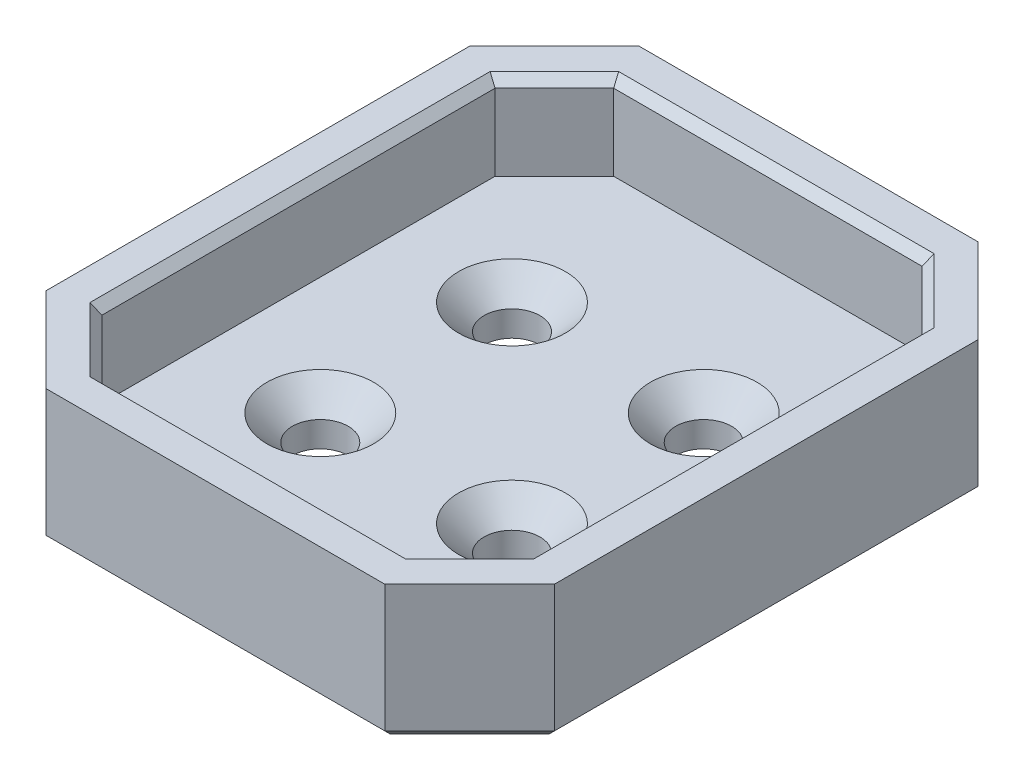
from build123d import *

# Parameters (mm, degrees)
SKETCH1_W                                      = 30
SKETCH1_H                                      = 35
BOSS_EXTRUDE1_DEPTH                            = 3
SKETCH2_W                                      = 30
SKETCH2_H                                      = 35
BOSS_EXTRUDE2_DEPTH                            = 5
CHAMFER1_SIZE                                  = 5
CSK_FOR_M3_FLAT_HEAD_MACHINE_SCREW1_AT_2_COUNT = 2
CSK_FOR_M3_FLAT_HEAD_MACHINE_SCREW1_AT_2_PITCH = 11.313708499
CSK_FOR_M3_FLAT_HEAD_MACHINE_SCREW1_AT_3_COUNT = 2
CSK_FOR_M3_FLAT_HEAD_MACHINE_SCREW1_AT_3_PITCH = 16
CSK_FOR_M3_FLAT_HEAD_MACHINE_SCREW1_AT_4_COUNT = 2
CSK_FOR_M3_FLAT_HEAD_MACHINE_SCREW1_AT_4_PITCH = 11.313708499
CHAMFER2_SIZE                                  = 0.5
CHAMFER3_SIZE                                  = 0.5


with BuildPart() as part:
    # Sketch1 → Boss-Extrude1 (new body)
    with BuildSketch(Plane(origin=(0, 0, 0), x_dir=(1, 0, 0), z_dir=(0, 1, 0))):
        Rectangle(SKETCH1_W, SKETCH1_H)
    extrude(amount=BOSS_EXTRUDE1_DEPTH)

    # Sketch2 → Boss-Extrude2 (add)
    with BuildSketch(Plane(origin=(0, 3, 0), x_dir=(1, 0, 0), z_dir=(0, 1, 0))):
        Rectangle(SKETCH2_W, SKETCH2_H)
        Polygon((12.6, -11.6), (12.6, 11.6), (9.1, 15.1), (-9.1, 15.1), (-12.6, 11.6), (-12.6, -11.6), (-9.1, -15.1), (9.1, -15.1), align=None, mode=Mode.SUBTRACT)
    extrude(amount=BOSS_EXTRUDE2_DEPTH)

    # Chamfer1
    chamfer1_edges = [part.edges().sort_by_distance(p)[0] for p in [
        (15, 4, 17.5),
        (-15, 4, 17.5),
        (-15, 4, -17.5),
        (15, 4, -17.5),
    ]]
    chamfer(chamfer1_edges, length=CHAMFER1_SIZE)

    # Sketch6 → CSK for M3 Flat Head Machine Screw1 (revolve, cut)
    with BuildSketch(Plane(origin=(-5.656854249, 3, -5.656854249), x_dir=(0, 0, 1), z_dir=(1, 0, 0))):
        Polygon((0, 0), (0, 3), (1.65, 3), (1.65, 1.5), (3.15, 0), align=None)
    csk_for_m3_flat_head_machine_screw1 = revolve(axis=Axis((-5.656854249, 9.35, -5.656854249), (0, -1, 0)), mode=Mode.SUBTRACT)

    # CSK for M3 Flat Head Machine Screw1 at 2: CSK for M3 Flat Head Machine Screw1 ×2
    with Locations(*[(i * CSK_FOR_M3_FLAT_HEAD_MACHINE_SCREW1_AT_2_PITCH, 0, 0) for i in range(1, CSK_FOR_M3_FLAT_HEAD_MACHINE_SCREW1_AT_2_COUNT)]):
        add(csk_for_m3_flat_head_machine_screw1, mode=Mode.SUBTRACT)

    # CSK for M3 Flat Head Machine Screw1 at 3: CSK for M3 Flat Head Machine Screw1 ×2
    with Locations(*[Vector(0.707106781, 0, 0.707106781) * (i * CSK_FOR_M3_FLAT_HEAD_MACHINE_SCREW1_AT_3_PITCH) for i in range(1, CSK_FOR_M3_FLAT_HEAD_MACHINE_SCREW1_AT_3_COUNT)]):
        add(csk_for_m3_flat_head_machine_screw1, mode=Mode.SUBTRACT)

    # CSK for M3 Flat Head Machine Screw1 at 4: CSK for M3 Flat Head Machine Screw1 ×2
    with Locations(*[(0, 0, i * CSK_FOR_M3_FLAT_HEAD_MACHINE_SCREW1_AT_4_PITCH) for i in range(1, CSK_FOR_M3_FLAT_HEAD_MACHINE_SCREW1_AT_4_COUNT)]):
        add(csk_for_m3_flat_head_machine_screw1, mode=Mode.SUBTRACT)

    # Chamfer2
    chamfer2_edges = [part.edges().sort_by_distance(p)[0] for p in [
        (-10.85, 8, -13.35),
        (-12.6, 8, 0),
        (-10.85, 8, 13.35),
        (0, 8, 15.1),
        (10.85, 8, 13.35),
        (12.6, 8, 0),
        (10.85, 8, -13.35),
        (0, 8, -15.1),
    ]]
    chamfer(chamfer2_edges, length=CHAMFER2_SIZE)

    # Chamfer3
    chamfer3_edges = [part.edges().sort_by_distance(p)[0] for p in [
        (15, 0, 0),
        (0, 0, 17.5),
        (-15, 0, 0),
        (0, 0, -17.5),
        (-12.5, 0, -15),
        (12.5, 0, -15),
        (-12.5, 0, 15),
        (12.5, 0, 15),
    ]]
    chamfer(chamfer3_edges, length=CHAMFER3_SIZE)


solid = part.part
